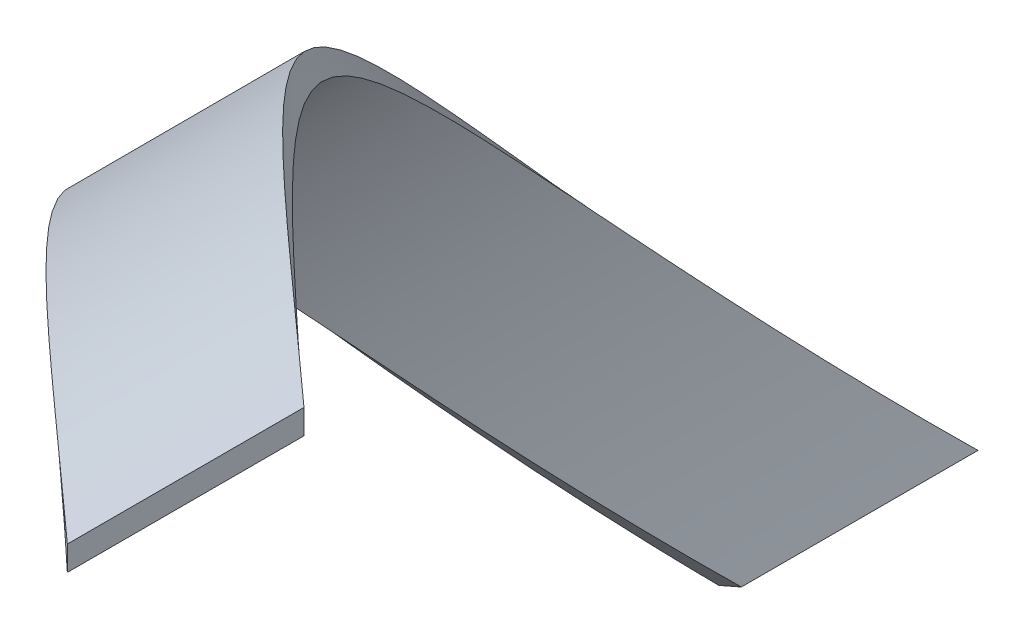
from build123d import *

# Parameters (mm, degrees)
SWEEP1_PITCH       = 445.870537374
SWEEP1_HEIGHT      = 140.805915703
SWEEP1_RADIUS      = 76
SWEEP1_START_ANGLE = 90
SKETCH2_W          = 25
SKETCH2_H          = 2.6


with BuildPart() as part:
    # Sweep1: sweep along a helix
    with BuildLine() as sweep1_path:
        add(Helix(SWEEP1_PITCH, SWEEP1_HEIGHT, SWEEP1_RADIUS, center=(0, 0, -411.77427784), direction=(0, 0, -1), lefthand=True, mode=Mode.PRIVATE).rotate(Axis((0, 0, -411.77427784), (0, 0, -1)), SWEEP1_START_ANGLE))
    # Sketch2 → Sweep1 (sweep)
    with BuildSketch(Plane(origin=(0, 0, 0), x_dir=(0, 0, -1), z_dir=(1, 0, 0))):
        with Locations((411.77427784, 77.3)):
            Rectangle(SKETCH2_W, SKETCH2_H)
    sweep(path=sweep1_path.line, is_frenet=True)


solid = part.part
